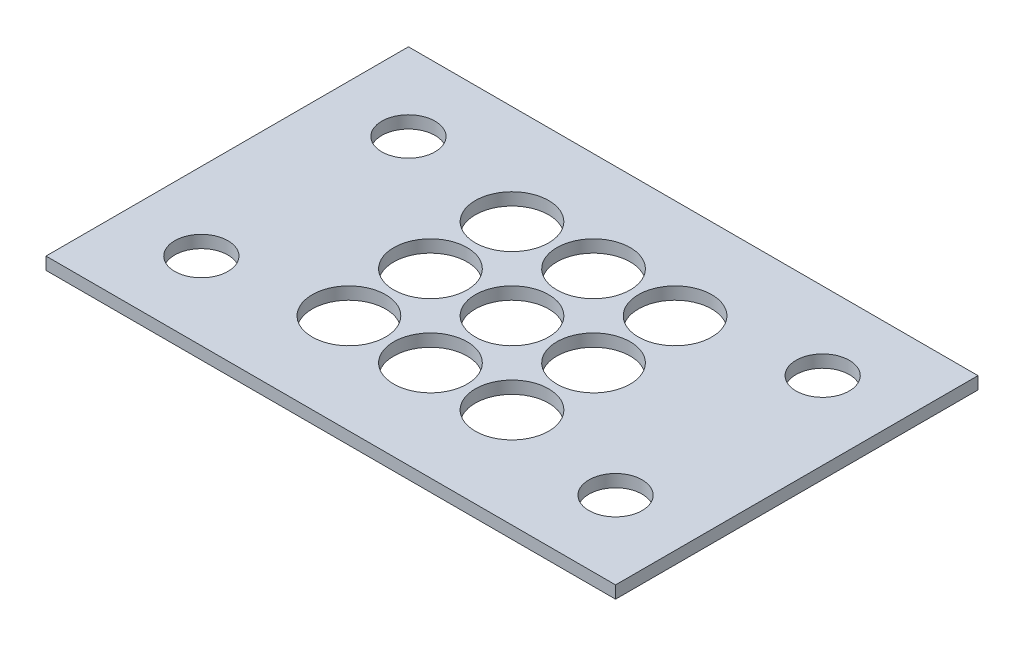
from build123d import *

# Parameters (mm, degrees)
SKETCH1_W           = 69.85
SKETCH1_H           = 44.45
SKETCH1_R           = 4.5
SKETCH1_R_2         = 3.2639
BOSS_EXTRUDE1_DEPTH = 1.524


with BuildPart() as part:
    # Sketch1 → Boss-Extrude1 (new body)
    with BuildSketch(Plane(origin=(0, 0, 0), x_dir=(1, 0, 0), z_dir=(0, 1, 0))):
        with Locations((34.925, 22.225)):
            Rectangle(SKETCH1_W, SKETCH1_H)
        with Locations((24.925, 12.225)):
            Circle(SKETCH1_R, mode=Mode.SUBTRACT)
        with Locations((24.925, 32.225)):
            Circle(SKETCH1_R, mode=Mode.SUBTRACT)
        with Locations((24.925, 22.225)):
            Circle(SKETCH1_R, mode=Mode.SUBTRACT)
        with Locations((34.925, 12.225)):
            Circle(SKETCH1_R, mode=Mode.SUBTRACT)
        with Locations((44.925, 12.225)):
            Circle(SKETCH1_R, mode=Mode.SUBTRACT)
        with Locations((34.925, 32.225)):
            Circle(SKETCH1_R, mode=Mode.SUBTRACT)
        with Locations((44.925, 32.225)):
            Circle(SKETCH1_R, mode=Mode.SUBTRACT)
        with Locations((44.925, 22.225)):
            Circle(SKETCH1_R, mode=Mode.SUBTRACT)
        with Locations((34.925, 22.225)):
            Circle(SKETCH1_R, mode=Mode.SUBTRACT)
        with Locations((60.325, 9.525)):
            Circle(SKETCH1_R_2, mode=Mode.SUBTRACT)
        with Locations((9.525, 9.525)):
            Circle(SKETCH1_R_2, mode=Mode.SUBTRACT)
        with Locations((60.325, 34.925)):
            Circle(SKETCH1_R_2, mode=Mode.SUBTRACT)
        with Locations((9.525, 34.925)):
            Circle(SKETCH1_R_2, mode=Mode.SUBTRACT)
    extrude(amount=BOSS_EXTRUDE1_DEPTH)


solid = part.part
